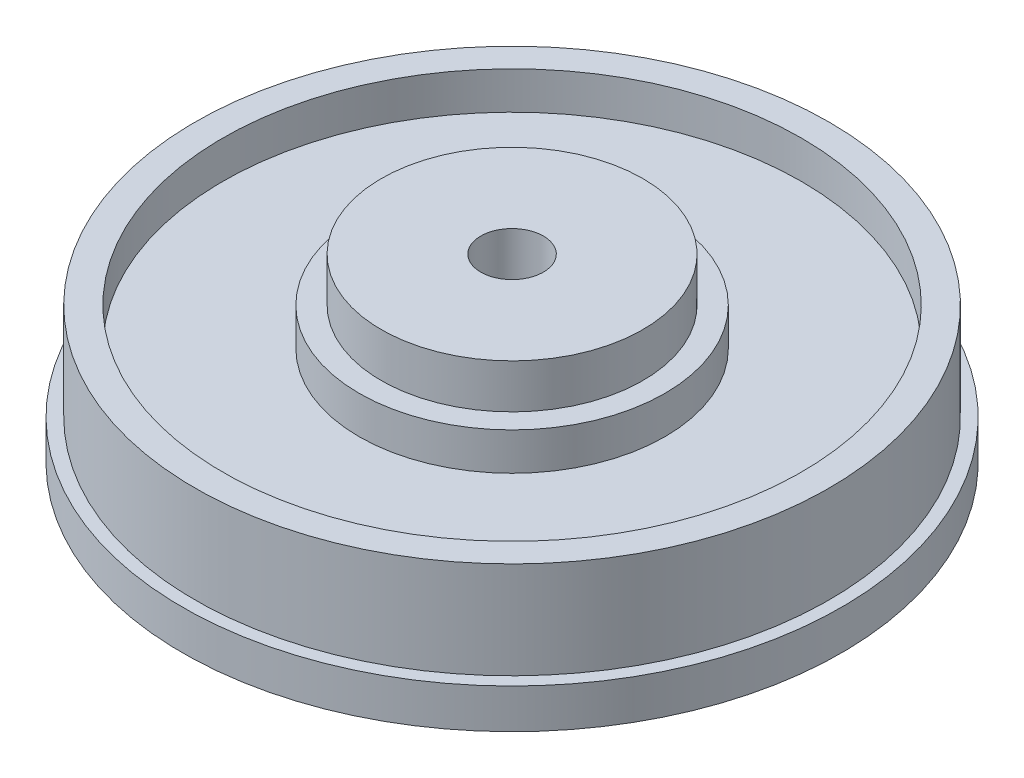
from build123d import *


with BuildPart() as part:
    # Esboço1 → Revolução1 (revolve)
    with BuildSketch(Plane.XY):
        Polygon((4.75, 0), (4.75, 27.4), (19.85, 27.4), (19.85, 20.7), (23.2, 20.7), (23.2, 15), (43.9, 15), (43.9, 20.7), (48.1, 20.7), (48.1, 6), (50, 6), (50, 0), (39.85, 0), (39.85, 2), (19.85, 2), (19.85, 0), align=None)
    revolve(axis=Axis((0, 0, 0), (0, 1, 0)))


solid = part.part
